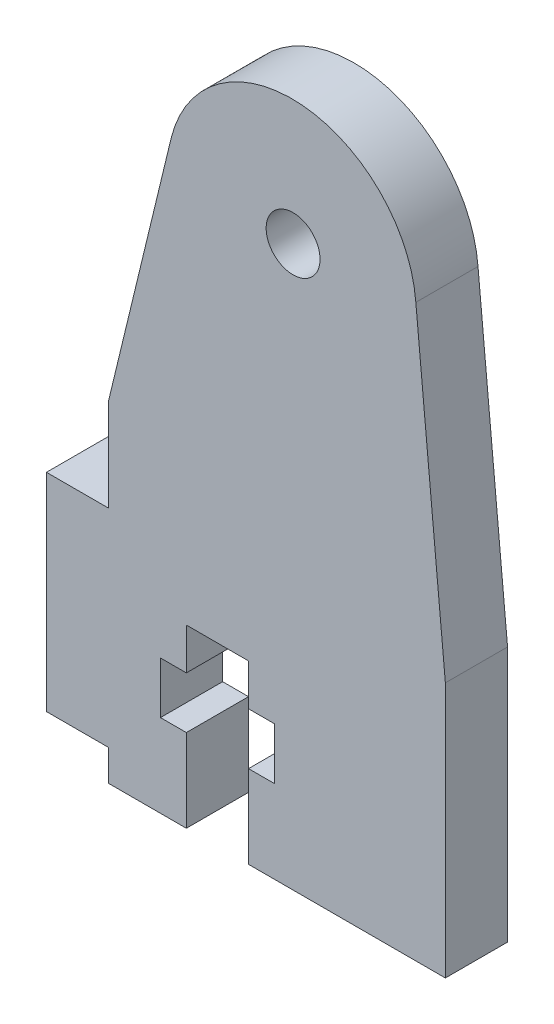
from build123d import *

# Parameters (mm, degrees)
MODEL_R             = 1.3
BOSS_EXTRUDE1_DEPTH = 3


with BuildPart() as part:
    # Model → Boss-Extrude1 (new body)
    with BuildSketch(Plane.XY):
        with BuildLine():
            Line((48.62361742, 20.481068056), (39.12638258, 20.481068056))
            Line((39.12638258, 20.481068056), (39.12638258, 24.481068056))
            Line((39.12638258, 24.481068056), (40.37638258, 24.481068056))
            Line((40.37638258, 24.481068056), (40.37638258, 26.981068056))
            Line((40.37638258, 26.981068056), (39.12638258, 26.981068056))
            Line((39.12638258, 26.981068056), (39.12638258, 28.981068056))
            Line((39.12638258, 28.981068056), (36.12638258, 28.981068056))
            Line((36.12638258, 28.981068056), (36.12638258, 26.981068056))
            Line((36.12638258, 26.981068056), (34.87638258, 26.981068056))
            Line((34.87638258, 26.981068056), (34.87638258, 24.488530086))
            Line((34.87638258, 24.488530086), (36.12638258, 24.488530086))
            Line((36.12638258, 24.488530086), (36.12638258, 20.488530086))
            Line((36.12638258, 20.488530086), (32.37638258, 20.488530086))
            Line((32.37638258, 20.488530086), (32.37638258, 21.988530086))
            Line((32.37638258, 21.988530086), (29.37638258, 21.988530086))
            Line((29.37638258, 21.988530086), (29.37638258, 31.988530086))
            Line((29.37638258, 31.988530086), (32.37638258, 31.988530086))
            Line((32.37638258, 31.988530086), (32.37638258, 36.488530086))
            Line((32.37638258, 36.488530086), (35.395249636, 48.968623875))
            ThreePointArc((35.395249636, 48.968623875), (41.708225131, 53.498846113), (47.198169486, 48.000020412))
            Line((47.198169486, 48.000020412), (48.62361742, 32.814680991))
            Line((48.62361742, 32.814680991), (48.62361742, 20.481068056))
        make_face()
        with Locations((41.27638258, 47.488530086)):
            Circle(MODEL_R, mode=Mode.SUBTRACT)
    extrude(amount=BOSS_EXTRUDE1_DEPTH)


solid = part.part
